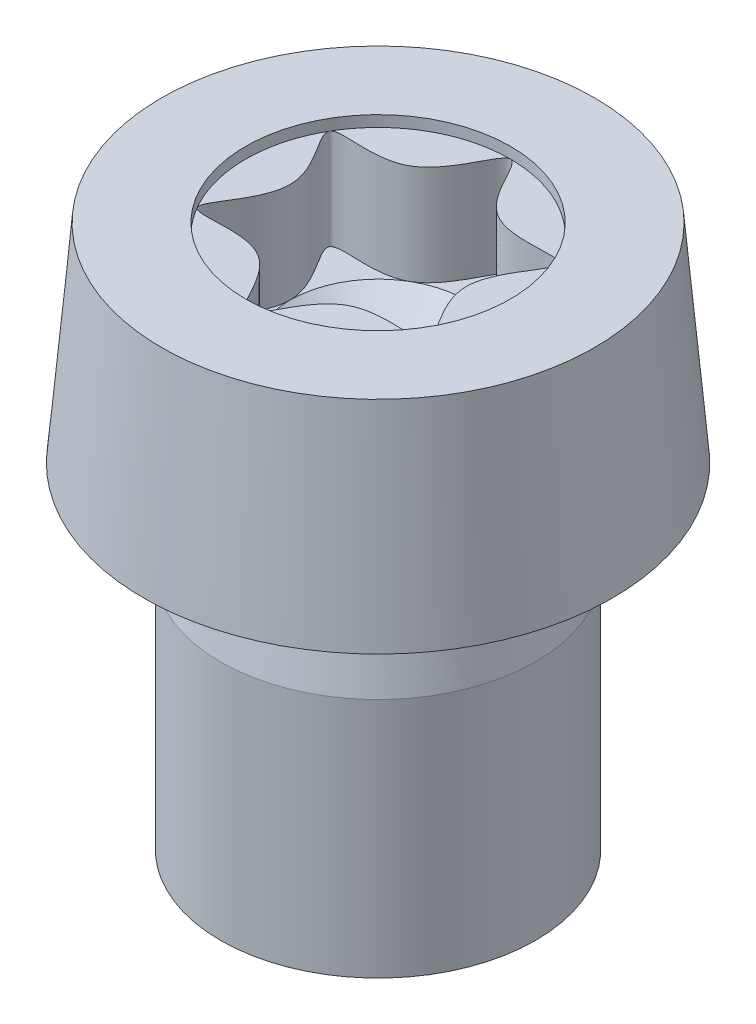
from build123d import *

# Parameters (mm, degrees)
FILLET1_R                 = 0.2
SOCKET_CUT_EXTRUDE1_DEPTH = 1.66
SKETCH3_R                 = 1.975
SOCKET_CUT_EXTRUDE2_DEPTH = 0.166


with BuildPart() as part:
    # Sketch1 → Body-Revolve (revolve)
    with BuildSketch(Plane.XY, mode=Mode.PRIVATE) as body_revolve_sk:
        Polygon((0, 8.1), (3.228785143, 8.1), (3.5, 5), (2.35, 5), (2.07, 5), (2.35, 3.6), (2.35, 0), (0, 0), align=None)
    revolve(body_revolve_sk.sketch.rotate(Axis((0, 0, 0), (0, 1, 0)), 90), axis=Axis((0, 0, 0), (0, 1, 0)))

    # Fillet1
    fillet1_edges = [part.edges().sort_by_distance(p)[0] for p in [
        (0, 5, 2.07),
    ]]
    fillet(fillet1_edges, radius=FILLET1_R)

    # Sketch2 → Socket-Cut-Extrude1 (cut)
    with BuildSketch(Plane(origin=(0, 8.1, 0), x_dir=(-1, 0, 0), z_dir=(0, 1, 0))):
        with BuildLine():
            add(Edge.make_bspline(
                [(0, -1.975), (-0.141989717, -1.975), (-0.425969151, -0.737800212), (-2.246123395, -1.296799947), (-0.851938302, 0), (-2.246123395, 1.296799947), (-0.425969151, 0.737800212), (0, 2.593599894), (0.425969151, 0.737800212), (2.246123395, 1.296799947), (0.851938302, 0), (2.246123395, -1.296799947), (0.425969151, -0.737800212), (0.141989717, -1.975), (0, -1.975)],
                knots=[0, 0, 0, 0, 0.083333333, 0.166666667, 0.25, 0.333333333, 0.416666667, 0.5, 0.583333333, 0.666666667, 0.75, 0.833333333, 0.916666667, 1, 1, 1, 1], degree=3))
        make_face()
    extrude(amount=-SOCKET_CUT_EXTRUDE1_DEPTH, mode=Mode.SUBTRACT)

    # Sketch3 → Socket-Cut-Extrude2 (cut)
    with BuildSketch(Plane(origin=(0, 8.1, 0), x_dir=(-1, 0, 0), z_dir=(0, 1, 0))):
        with Locations(Location((0, 0, 0), (0, 0, 90))):
            Circle(SKETCH3_R)
    extrude(amount=-SOCKET_CUT_EXTRUDE2_DEPTH, mode=Mode.SUBTRACT)

    # Sketch4 → Drill-Cut-Revolve (revolve, cut)
    with BuildSketch(Plane.XY, mode=Mode.PRIVATE) as drill_cut_revolve_sk:
        Polygon((0, 6.44), (1.316666667, 6.44), (0, 5.31), align=None)
    revolve(drill_cut_revolve_sk.sketch.rotate(Axis((0, 0, 0), (0, 1, 0)), 270), axis=Axis((0, 0, 0), (0, 1, 0)), mode=Mode.SUBTRACT)


solid = part.part
